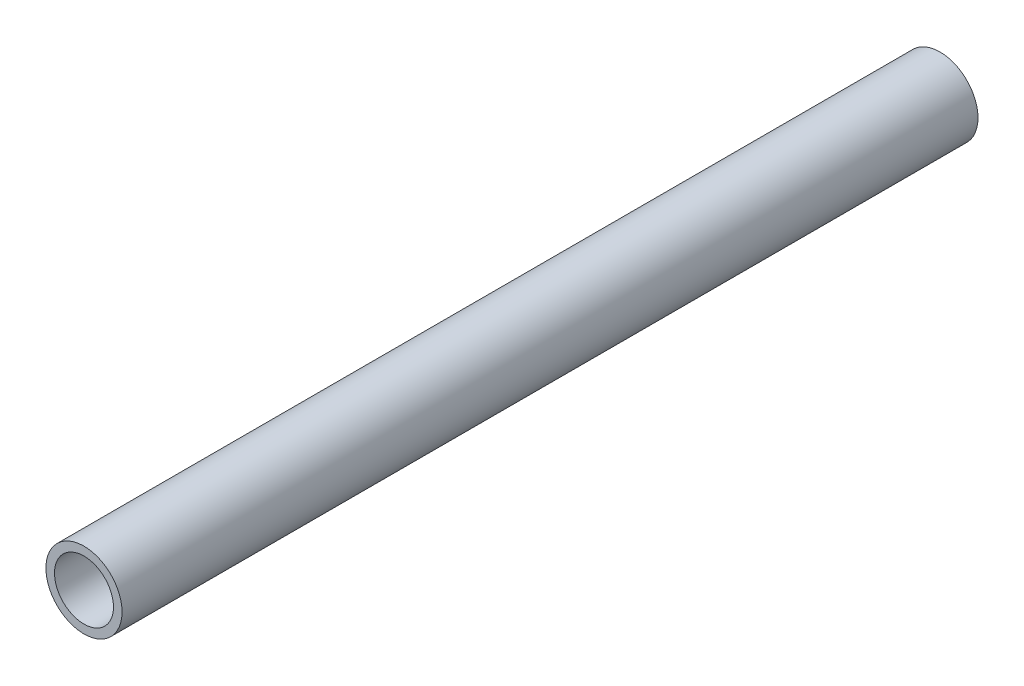
from build123d import *

# Parameters (mm, degrees)
SKETCH1_R           = 13.335
SKETCH1_R_2         = 10.335
BOSS_EXTRUDE1_DEPTH = 150


with BuildPart() as part:
    # Sketch1 → Boss-Extrude1 (new body, symmetric)
    with BuildSketch(Plane.XY):
        Circle(SKETCH1_R)
        Circle(SKETCH1_R_2, mode=Mode.SUBTRACT)
    extrude(amount=BOSS_EXTRUDE1_DEPTH, both=True)


solid = part.part
